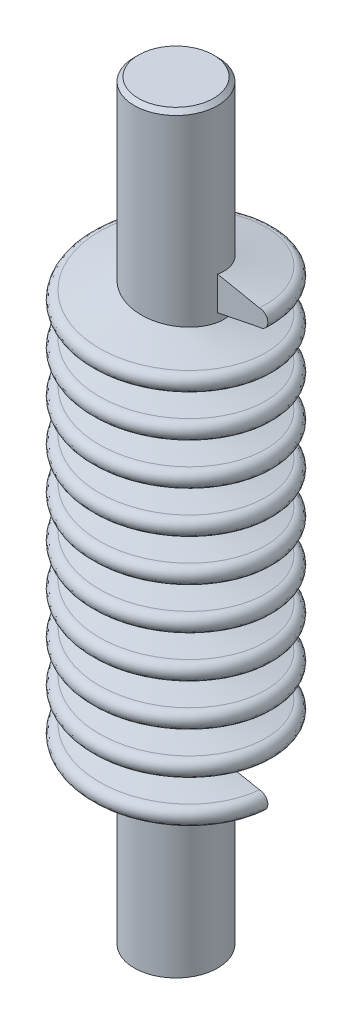
from build123d import *

# Parameters (mm, degrees)
SKETCH1_R           = 5
BOSS_EXTRUDE2_DEPTH = 90
CHAMFER1_SIZE       = 0.5
SWEEP1_PITCH        = 5
SWEEP1_HEIGHT       = 50
SWEEP1_RADIUS       = 5
SWEEP1_START_ANGLE  = 90


with BuildPart() as part:
    # Sketch1 → Boss-Extrude2 (new body)
    with BuildSketch(Plane(origin=(0, 0, 0), x_dir=(1, 0, 0), z_dir=(0, 1, 0))):
        Circle(SKETCH1_R)
    extrude(amount=BOSS_EXTRUDE2_DEPTH)

    # Chamfer1
    chamfer1_edges = [part.edges().sort_by_distance(p)[0] for p in [
        (-5, 90, 0),
    ]]
    chamfer(chamfer1_edges, length=CHAMFER1_SIZE)

    # Sweep1: sweep along a helix
    with BuildLine() as sweep1_path:
        add(Helix(SWEEP1_PITCH, SWEEP1_HEIGHT, SWEEP1_RADIUS, center=(0, 70, 0), direction=(0, -1, 0), lefthand=True, mode=Mode.PRIVATE).rotate(Axis((0, 70, 0), (0, -1, 0)), SWEEP1_START_ANGLE))
    # Sketch4 → Sweep1 (sweep)
    with BuildSketch(Plane.XY):
        with BuildLine():
            Line((4.781011006, 72), (5, 72))
            Line((5, 72), (10, 71))
            ThreePointArc((10, 71), (11, 70), (10, 69))
            Line((10, 69), (5, 68))
            Line((5, 68), (4.781011006, 68))
            Line((4.781011006, 68), (4.781011006, 72))
        make_face()
    sweep(path=sweep1_path.line, is_frenet=True)


solid = part.part
